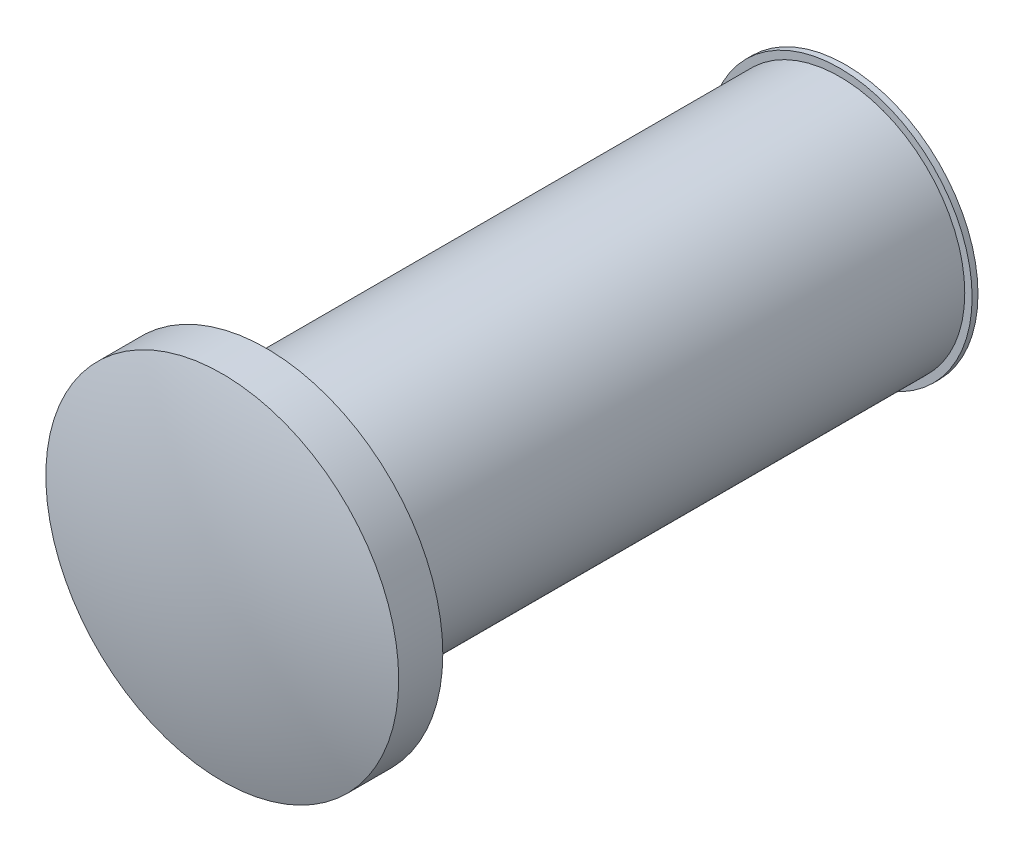
from build123d import *

# Parameters (mm, degrees)
SKETCH1_R           = 1.0795
BOSS_EXTRUDE1_DEPTH = 4.953
SKETCH2_R           = 1.524
BOSS_EXTRUDE2_DEPTH = 0.381
DOME1_FACE_RADIUS   = 1.524
DOME1_HEIGHT        = 0.2286
SKETCH3_R           = 1.143
BOSS_EXTRUDE3_DEPTH = 0.0508
SKETCH4_R           = 1.0668
CUT_EXTRUDE1_DEPTH  = 0.127


with BuildPart() as part:
    # Sketch1 → Boss-Extrude1 (new body)
    with BuildSketch(Plane.XY):
        Circle(SKETCH1_R)
    extrude(amount=BOSS_EXTRUDE1_DEPTH)

    # Sketch2 → Boss-Extrude2 (add)
    with BuildSketch(Plane.XY.offset(4.953)):
        Circle(SKETCH2_R)
    extrude(amount=BOSS_EXTRUDE2_DEPTH)

    # Dome1: a dome of height H over a round flat face of radius A is a cap of a sphere of radius (A * A + H * H) / (2 * H)
    dome1_r = (DOME1_FACE_RADIUS * DOME1_FACE_RADIUS + DOME1_HEIGHT * DOME1_HEIGHT) / (2 * DOME1_HEIGHT)
    dome1_base = Plane((0, 0, 5.334), z_dir=(0, 0, 1))
    with Locations(dome1_base.offset(DOME1_HEIGHT - dome1_r)):
        dome1_ball = Sphere(dome1_r, mode=Mode.PRIVATE)
    add(split(dome1_ball, bisect_by=dome1_base, keep=Keep.TOP, mode=Mode.PRIVATE))

    # Sketch3 → Boss-Extrude3 (add)
    with BuildSketch(Plane(origin=(0, 0, 0), x_dir=(-1, 0, 0), z_dir=(0, 0, -1))):
        Circle(SKETCH3_R)
    extrude(amount=BOSS_EXTRUDE3_DEPTH)

    # Sketch4 → Cut-Extrude1 (cut)
    with BuildSketch(Plane(origin=(0, 0, -0.0508), x_dir=(-1, 0, 0), z_dir=(0, 0, -1))):
        Circle(SKETCH4_R)
    extrude(amount=-CUT_EXTRUDE1_DEPTH, mode=Mode.SUBTRACT)


solid = part.part
